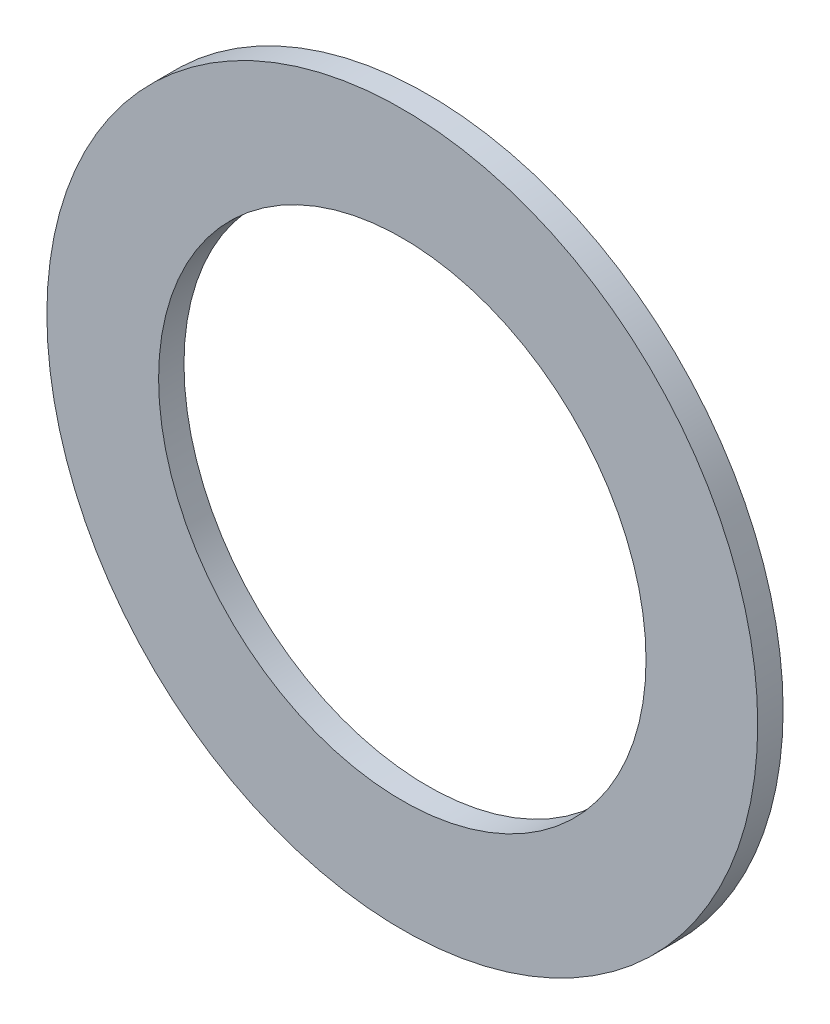
from build123d import *

# Parameters (mm, degrees)
ESQUISSE1_R        = 35
ESQUISSE1_R_2      = 24
BOSS_EXTRU_1_DEPTH = 2.5


with BuildPart() as part:
    # Esquisse1 → Boss.-Extru.1 (new body)
    with BuildSketch(Plane.XY):
        with Locations((-0.851831778, 0)):
            Circle(ESQUISSE1_R)
        with Locations((-0.851831778, 0)):
            Circle(ESQUISSE1_R_2, mode=Mode.SUBTRACT)
    extrude(amount=BOSS_EXTRU_1_DEPTH)


solid = part.part
